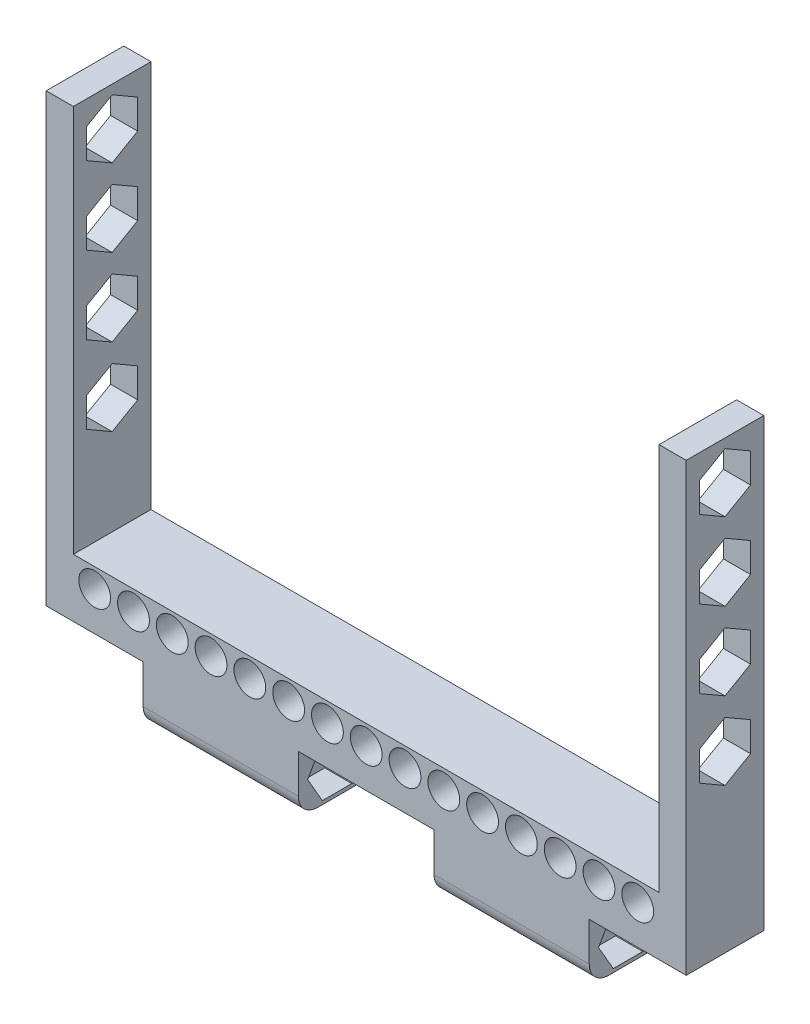
from build123d import *

# Parameters (mm, degrees)
SKETCH_1_W                 = 165
SKETCH_1_H                 = 20
EXTRUDE_1_DEPTH            = 15
SKETCH_2_W                 = 7
SKETCH_2_H                 = 20
EXTRUDE_2_DEPTH            = 100
SKETCH_3_R                 = 4.1
CUT_EXTRUDE_1_DEPTH        = 21
PATTERN_LINEAR_1_COUNT     = 8
PATTERN_LINEAR_1_PITCH     = 10
PATTERN_LINEAR_1_COL_COUNT = 8
PATTERN_LINEAR_1_COL_PITCH = 10
CUT_EXTRUDE_2_DEPTH        = 166
SKETCH_5_W                 = 40
SKETCH_5_H                 = 20
EXTRUDE_3_DEPTH            = 15
SKETCH_6_R                 = 4.2
CUT_EXTRUDE_4_DEPTH        = 141
CUT_EXTRUDE_5_DEPTH        = 7
CUT_EXTRUDE_6_DEPTH        = 7
CUT_EXTRUDE_7_DEPTH        = 7
CUT_EXTRUDE_8_DEPTH        = 7
FILLET_1_R                 = 5
FILLET_2_R                 = 5
PATTERN_LINEAR_2_COUNT     = 4
PATTERN_LINEAR_2_PITCH     = 20


with BuildPart() as part:
    # Эскиз1 → Бобышка-Вытянуть1 (new body)
    with BuildSketch(Plane(origin=(0, 0, 0), x_dir=(1, 0, 0), z_dir=(0, 1, 0))):
        with Locations((-82.5, -10)):
            Rectangle(SKETCH_1_W, SKETCH_1_H)
    extrude(amount=EXTRUDE_1_DEPTH)

    # Эскиз2 → Бобышка-Вытянуть2 (add)
    with BuildSketch(Plane(origin=(0, 15, 0), x_dir=(1, 0, 0), z_dir=(0, 1, 0))):
        with Locations((-161.5, -10)):
            Rectangle(SKETCH_2_W, SKETCH_2_H)
        with Locations((-3.5, -10)):
            Rectangle(SKETCH_2_W, SKETCH_2_H)
    extrude(amount=EXTRUDE_2_DEPTH)

    # Эскиз3 → Вырез-Вытянуть1 (cut, through all)
    with BuildSketch(Plane.XY.offset(20)):
        with Locations((-82.5, 10)):
            Circle(SKETCH_3_R)
    cut_extrude_1 = extrude(amount=-CUT_EXTRUDE_1_DEPTH, mode=Mode.SUBTRACT)

    # Линейный массив1: Вырез-Вытянуть1 ×8
    with Locations(*[(-i * PATTERN_LINEAR_1_PITCH, 0, 0) for i in range(1, PATTERN_LINEAR_1_COUNT)]):
        add(cut_extrude_1, mode=Mode.SUBTRACT)

    # Линейный массив1 col: Вырез-Вытянуть1 ×8
    with Locations(*[(i * PATTERN_LINEAR_1_COL_PITCH, 0, 0) for i in range(1, PATTERN_LINEAR_1_COL_COUNT)]):
        add(cut_extrude_1, mode=Mode.SUBTRACT)

    # Эскиз4 → Вырез-Вытянуть2 (cut, through all)
    with BuildSketch(Plane.ZY.offset(165)):
        Polygon((10, 97.4), (16.581793069, 101.2), (16.581793069, 108.8), (10, 112.6), (3.418206931, 108.8), (3.418206931, 101.2), align=None)
    cut_extrude_2 = extrude(amount=-CUT_EXTRUDE_2_DEPTH, mode=Mode.SUBTRACT)

    # Эскиз5 → Бобышка-Вытянуть3 (add)
    with BuildSketch(Plane.XZ):
        with Locations((-120, 10)):
            Rectangle(SKETCH_5_W, SKETCH_5_H)
        with Locations((-45, 10)):
            Rectangle(SKETCH_5_W, SKETCH_5_H)
    extrude(amount=EXTRUDE_3_DEPTH)

    # Эскиз6 → Вырез-Вытянуть4 (cut, through all)
    with BuildSketch(Plane.ZY.offset(140)):
        with Locations((10, -7.5)):
            Circle(SKETCH_6_R)
    extrude(amount=-CUT_EXTRUDE_4_DEPTH, mode=Mode.SUBTRACT)

    # Эскиз7 → Вырез-Вытянуть5 (cut)
    with BuildSketch(Plane.ZY.offset(140)):
        Polygon((17.6, -7.5), (13.8, -0.918206931), (6.2, -0.918206931), (2.4, -7.5), (6.2, -14.081793069), (13.8, -14.081793069), align=None)
    extrude(amount=-CUT_EXTRUDE_5_DEPTH, mode=Mode.SUBTRACT)

    # Эскиз8 → Вырез-Вытянуть6 (cut)
    with BuildSketch(Plane(origin=(-100, 0, 0), x_dir=(0, 0, -1), z_dir=(1, 0, 0))):
        Polygon((-17.6, -7.5), (-13.8, -14.081793069), (-6.2, -14.081793069), (-2.4, -7.5), (-6.2, -0.918206931), (-13.8, -0.918206931), align=None)
    extrude(amount=-CUT_EXTRUDE_6_DEPTH, mode=Mode.SUBTRACT)

    # Эскиз9 → Вырез-Вытянуть7 (cut)
    with BuildSketch(Plane.ZY.offset(65)):
        Polygon((17.6, -7.5), (13.8, -0.918206931), (6.2, -0.918206931), (2.4, -7.5), (6.2, -14.081793069), (13.8, -14.081793069), align=None)
    extrude(amount=-CUT_EXTRUDE_7_DEPTH, mode=Mode.SUBTRACT)

    # Эскиз10 → Вырез-Вытянуть8 (cut)
    with BuildSketch(Plane(origin=(-25, 0, 0), x_dir=(0, 0, -1), z_dir=(1, 0, 0))):
        Polygon((-2.4, -7.5), (-6.2, -0.918206931), (-13.8, -0.918206931), (-17.6, -7.5), (-13.8, -14.081793069), (-6.2, -14.081793069), align=None)
    extrude(amount=-CUT_EXTRUDE_8_DEPTH, mode=Mode.SUBTRACT)

    # Скругление1
    fillet_1_edges = [part.edges().sort_by_distance(p)[0] for p in [
        (-45, -15, 0),
        (-45, -15, 20),
    ]]
    fillet(fillet_1_edges, radius=FILLET_1_R)

    # Скругление2
    fillet_2_edges = [part.edges().sort_by_distance(p)[0] for p in [
        (-120, -15, 0),
        (-120, -15, 20),
    ]]
    fillet(fillet_2_edges, radius=FILLET_2_R)

    # Линейный массив2: Вырез-Вытянуть2 ×4
    with Locations(*[(0, -i * PATTERN_LINEAR_2_PITCH, 0) for i in range(1, PATTERN_LINEAR_2_COUNT)]):
        add(cut_extrude_2, mode=Mode.SUBTRACT)


solid = part.part
